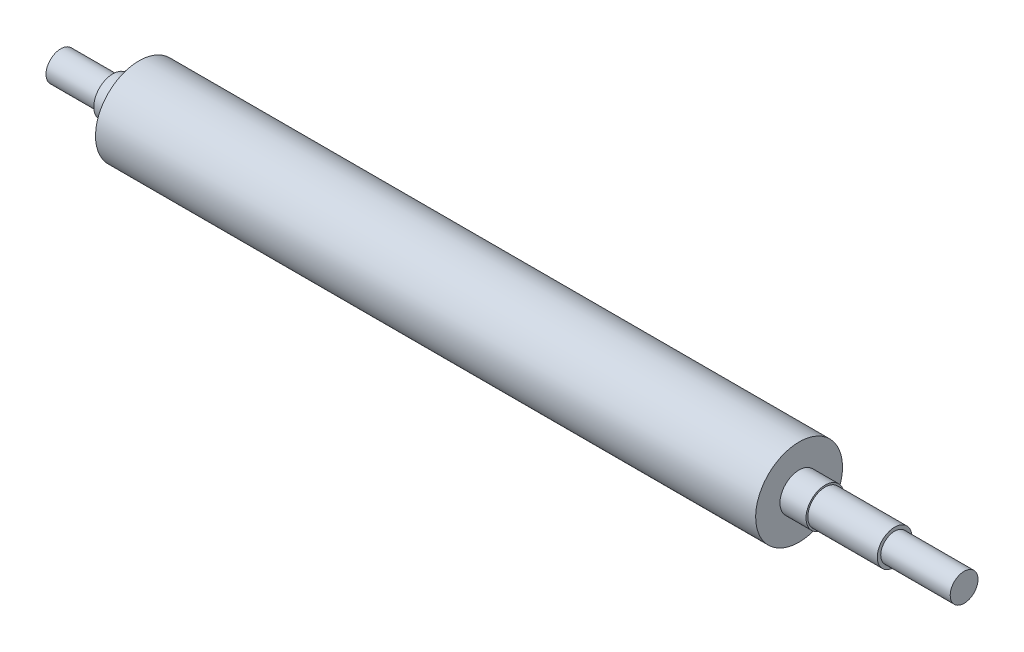
from build123d import *

# Parameters (mm, degrees)
CUT_EXTRUDE_1_DEPTH = 3.5


with BuildPart() as part:
    # 草图1 → 旋转1 (revolve)
    with BuildSketch(Plane.XY):
        Polygon((-190, 25), (190, 25), (190, 11), (205, 11), (205, 10), (245, 10), (245, 8), (285, 8), (285, 0), (-235, 0), (-235, 8.5), (-205, 8.5), (-205, 11), (-190, 11), align=None)
    revolve(axis=Axis((-235, 0, 0), (1, 0, 0)))

    # 草图3 → 切除-拉伸1 (cut)
    with BuildSketch(Plane(origin=(0, -8, 0), x_dir=(-1, 0, 0), z_dir=(0, -1, 0))):
        with BuildLine():
            Line((-280, 3), (-250, 3))
            ThreePointArc((-250, 3), (-247, 0), (-250, -3))
            Line((-250, -3), (-280, -3))
            ThreePointArc((-280, -3), (-283, 0), (-280, 3))
        make_face()
    extrude(amount=-CUT_EXTRUDE_1_DEPTH, mode=Mode.SUBTRACT)


solid = part.part
